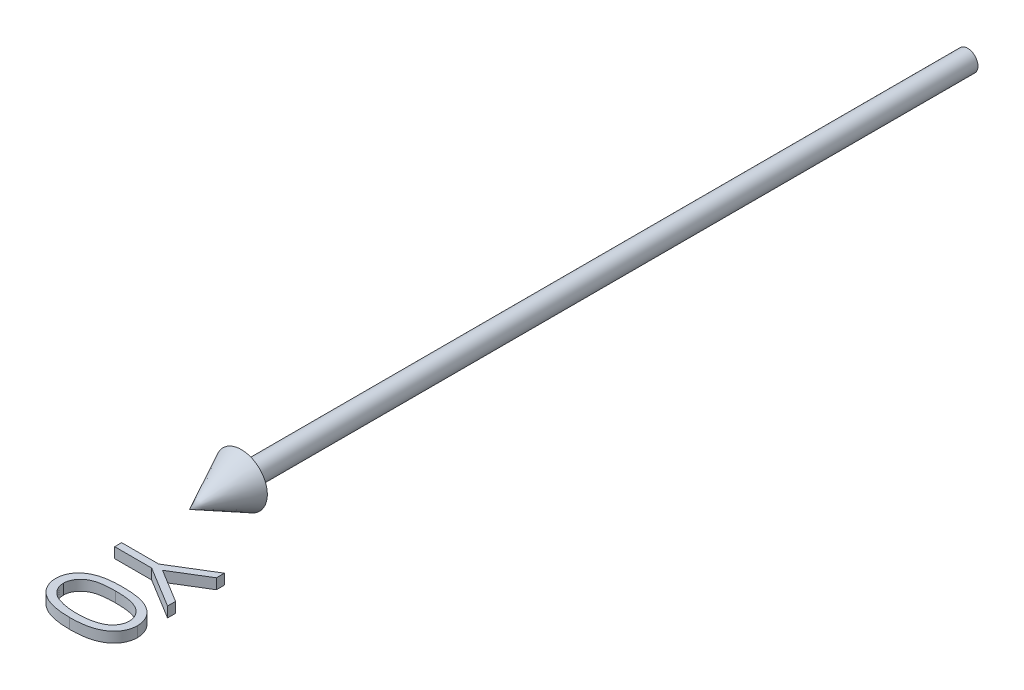
from build123d import *

# Parameters (mm, degrees)
BOSS_EXTRUDE1_DEPTH        = 1
BOSS_EXTRUDE1_DEPTH_BACK   = 1
BOSS_EXTRUDE1_2_DEPTH      = 1
BOSS_EXTRUDE1_2_DEPTH_BACK = 1


with BuildPart() as part:
    # Sketch2 → Revolve1 (revolve)
    with BuildSketch(Plane(origin=(0, 0, 0), x_dir=(1, 0, 0), z_dir=(0, 1, 0))):
        Polygon((0, -150), (5, -140), (2, -140), (2, 0), (0, 0), align=None)
    revolve(axis=Axis((0, 0, -41.949952025), (0, 0, 1)))


with BuildPart() as body_2:
    # Sketch3 → Boss-Extrude1 (new, two sides: drawn at the far end of the back side and taken through both)
    with BuildSketch(Plane(origin=(0, 0, 0), x_dir=(1, 0, 0), z_dir=(0, 1, 0)).offset(-BOSS_EXTRUDE1_DEPTH_BACK)):
        Polygon((15, -158.269230769), (15, -159.810697115), (8.5546875, -163.753004808), (15, -167.689302885), (15, -169.230769231), (7.130408654, -164.423076923), (0, -164.423076923), (0, -163.076923077), (7.130408654, -163.076923077), align=None)
    extrude(amount=BOSS_EXTRUDE1_DEPTH + BOSS_EXTRUDE1_DEPTH_BACK)


with BuildPart() as body_3:
    # Sketch3 → Boss-Extrude1 2 (new, two sides: drawn at the far end of the back side and taken through both)
    with BuildSketch(Plane(origin=(0, 0, 0), x_dir=(1, 0, 0), z_dir=(0, 1, 0)).offset(-BOSS_EXTRUDE1_2_DEPTH_BACK)):
        with BuildLine():
            add(Edge.make_bspline(
                [(7.493990385, -170.384615385), (7.734407761, -170.386021177), (8.201421979, -170.388751948), (8.881927587, -170.419130896), (9.520328829, -170.469596645), (10.116656244, -170.538756826), (10.67106384, -170.622919561), (11.182069829, -170.73527177), (11.652039951, -170.86304051), (12.082504599, -171.011123814), (12.479270571, -171.17820954), (12.849648816, -171.360087578), (13.193169112, -171.563876698), (13.51499205, -171.778277961), (13.811525932, -172.011126158), (14.082209196, -172.259965314), (14.327205285, -172.527263814), (14.549430068, -172.807735101), (14.743016183, -173.103151676), (14.917450141, -173.404406832), (15.060618757, -173.716816459), (15.178257413, -174.037531283), (15.272518287, -174.365618631), (15.33779376, -174.702434135), (15.378703934, -175.048059165), (15.382626206, -175.281334124), (15.384615385, -175.399639423)],
                knots=[0, 0, 0, 0, 1.646377244, 3.198111528, 4.663803227, 6.031090796, 7.308794487, 8.502186765, 9.612154809, 10.642545331, 11.617106989, 12.558866172, 13.465886467, 14.35053239, 15.20542558, 16.045215227, 16.865619885, 17.686225247, 18.492864914, 19.282407821, 20.068097601, 20.842842034, 21.620163247, 22.403093475, 23.190129512, 24, 24, 24, 24], degree=3))
            add(Edge.make_bspline(
                [(15.384615385, -175.399639423), (15.382524748, -175.518934331), (15.37836713, -175.756174369), (15.338407376, -176.106918834), (15.272102563, -176.449560327), (15.178155529, -176.782638065), (15.061602629, -177.108888007), (14.915514984, -177.425758325), (14.745462696, -177.735217247), (14.545646079, -178.03234705), (14.322864895, -178.320409687), (14.071024886, -178.592329529), (13.792668946, -178.848131325), (13.490775244, -179.091025491), (13.159553452, -179.314120908), (12.80476441, -179.526578475), (12.42020356, -179.716744343), (12.01228727, -179.899892951), (11.569728732, -180.057980037), (11.095022615, -180.200549659), (10.582561815, -180.315745239), (10.035035049, -180.411699263), (9.450431549, -180.486034532), (8.830004483, -180.540174426), (8.173345666, -180.568773362), (7.724383455, -180.574159224), (7.493990385, -180.576923077)],
                knots=[0, 0, 0, 0, 0.810914788, 1.612654377, 2.396697861, 3.181598691, 3.963628158, 4.749916497, 5.551656086, 6.361998678, 7.18212741, 8.025565596, 8.878627764, 9.750805457, 10.657531673, 11.591944965, 12.560506719, 13.57287815, 14.630710178, 15.753379473, 16.941251878, 18.199788006, 19.531962791, 20.947069417, 22.433333509, 24, 24, 24, 24], degree=3))
            add(Edge.make_bspline(
                [(7.493990385, -180.576923077), (7.264603065, -180.57412712), (6.817651229, -180.568679313), (6.163935199, -180.540532539), (5.546842359, -180.484828024), (4.964654956, -180.415930328), (4.420829624, -180.31778651), (3.910195243, -180.206214286), (3.437158505, -180.067541988), (2.996933984, -179.911609635), (2.59101622, -179.732435171), (2.209779717, -179.540588588), (1.855280169, -179.32943513), (1.524063192, -179.105009222), (1.219551287, -178.864179628), (0.940991864, -178.607294661), (0.688568659, -178.334158793), (0.462743585, -178.045444877), (0.265252974, -177.743640803), (0.088728132, -177.435214818), (-0.05451083, -177.114011014), (-0.175450263, -176.787167889), (-0.269613426, -176.451601462), (-0.334086308, -176.107640881), (-0.37942892, -175.756412602), (-0.382880577, -175.518975604), (-0.384615385, -175.399639423)],
                knots=[0, 0, 0, 0, 1.56130642, 3.042141888, 4.451772327, 5.777565838, 7.030558081, 8.211376819, 9.333164717, 10.383253789, 11.387583522, 12.350962576, 13.286244149, 14.193812918, 15.072134482, 15.925989337, 16.770211267, 17.600669898, 18.417446232, 19.22325363, 20.01647746, 20.807971184, 21.593601364, 22.38506573, 23.188331689, 24, 24, 24, 24], degree=3))
            add(Edge.make_bspline(
                [(-0.384615385, -175.399639423), (-0.382607064, -175.28133893), (-0.378647048, -175.048073448), (-0.338013359, -174.702378996), (-0.271753502, -174.36608879), (-0.181772946, -174.038530561), (-0.067412994, -173.719033953), (0.078048627, -173.410728753), (0.246761479, -173.109543308), (0.438703921, -172.816851937), (0.658664961, -172.538233163), (0.901935338, -172.272090663), (1.174616769, -172.025144432), (1.47234457, -171.795214565), (1.792592519, -171.577023606), (2.138515298, -171.375231471), (2.512363768, -171.193708194), (2.911320013, -171.022877938), (3.34494836, -170.87229139), (3.81742511, -170.740278675), (4.33136389, -170.63022761), (4.88523897, -170.541723973), (5.479464905, -170.468761629), (6.115087943, -170.419369857), (6.791559687, -170.388727754), (7.255574099, -170.386011189), (7.493990385, -170.384615385)],
                knots=[0, 0, 0, 0, 0.810940842, 1.599017053, 2.38298203, 3.159479784, 3.926441347, 4.70693857, 5.494146311, 6.292334103, 7.104379492, 7.925868426, 8.762126819, 9.623561095, 10.503686106, 11.41783325, 12.366995289, 13.351843594, 14.392337808, 15.512229747, 16.713911458, 17.994391108, 19.357476964, 20.818259213, 22.365182633, 24, 24, 24, 24], degree=3))
        make_face()
        with BuildLine():
            add(Edge.make_bspline(
                [(7.5, -171.730769231), (7.299648434, -171.731281147), (6.910805384, -171.732274675), (6.345762838, -171.758229821), (5.81874714, -171.793587955), (5.329089137, -171.839193526), (4.878446191, -171.906920408), (4.463719097, -171.982806775), (4.087101973, -172.075155292), (3.746012653, -172.1844211), (3.434655082, -172.308869447), (3.14495103, -172.444768924), (2.873388081, -172.590682563), (2.622724417, -172.754267227), (2.390464856, -172.93181246), (2.177276851, -173.123609805), (1.984090593, -173.329321947), (1.754856367, -173.614094986), (1.515171332, -173.988196995), (1.309023902, -174.461969146), (1.17863499, -174.949003658), (1.16209952, -175.279667143), (1.153846154, -175.444711538)],
                knots=[0, 0, 0, 0, 1.459116078, 2.831857795, 4.118796693, 5.306371758, 6.412361096, 7.436813035, 8.376339383, 9.234574298, 10.043323891, 10.816788787, 11.564361537, 12.286735248, 12.994408768, 13.691741332, 14.372975427, 15.047457468, 16.352811911, 17.594285292, 18.799233213, 20, 20, 20, 20], degree=3))
            add(Edge.make_bspline(
                [(1.153846154, -175.444711538), (1.160693786, -175.610815846), (1.174374912, -175.942681516), (1.306369501, -176.427540638), (1.50552467, -176.898241796), (1.741013979, -177.26712154), (1.965278248, -177.547761012), (2.156483884, -177.748833827), (2.370580458, -177.933385463), (2.60157744, -178.108422927), (2.853888087, -178.268961822), (3.126299124, -178.414946698), (3.419567029, -178.548161045), (3.624294482, -178.624056956), (3.728966346, -178.662860577)],
                knots=[0, 0, 0, 0, 1.353760809, 2.704726607, 4.075137775, 5.516104923, 6.260822281, 7.007110065, 7.778089737, 8.566572457, 9.372053459, 10.217411131, 11.088608312, 12, 12, 12, 12], degree=3))
            add(Edge.make_bspline(
                [(3.728966346, -178.662860577), (3.862808087, -178.708082439), (4.134564219, -178.799902212), (4.556122728, -178.918238388), (4.998420288, -179.011432956), (5.458813645, -179.095275952), (5.940698078, -179.152503334), (6.442582581, -179.198565391), (6.964845562, -179.225696907), (7.319681238, -179.229060126), (7.5, -179.230769231)],
                knots=[0, 0, 0, 0, 0.884706709, 1.796334032, 2.740027952, 3.714592787, 4.726048262, 5.777819803, 6.87074269, 8, 8, 8, 8], degree=3))
            add(Edge.make_bspline(
                [(7.5, -179.230769231), (7.680314886, -179.228884271), (8.033092983, -179.22519643), (8.549207658, -179.20096698), (9.04026198, -179.162032269), (9.50670142, -179.109334992), (9.947695768, -179.036992774), (10.363876079, -178.950116971), (10.755130158, -178.848265059), (11.122467014, -178.731437881), (11.464566341, -178.599775268), (11.782172956, -178.454327558), (12.076970622, -178.299115145), (12.348113155, -178.1304996), (12.596824432, -177.950519597), (12.818115455, -177.754415434), (13.018845343, -177.549968218), (13.247970631, -177.263608821), (13.481592187, -176.888719021), (13.696588299, -176.422237671), (13.820052411, -175.936792054), (13.837459641, -175.608620108), (13.846153846, -175.444711538)],
                knots=[0, 0, 0, 0, 1.313668642, 2.570134578, 3.763346207, 4.902004944, 5.98888779, 7.017888835, 7.998425394, 8.933058446, 9.82474457, 10.667209444, 11.476765193, 12.250262638, 12.991704352, 13.7104269, 14.401925311, 15.076585796, 16.378385137, 17.609787933, 18.806186071, 20, 20, 20, 20], degree=3))
            add(Edge.make_bspline(
                [(13.846153846, -175.444711538), (13.837458863, -175.278802035), (13.820053056, -174.94668078), (13.696912054, -174.456295073), (13.483593851, -173.986490757), (13.246461982, -173.614608662), (13.022901506, -173.328610561), (12.828492468, -173.126655973), (12.614659534, -172.937849461), (12.383383302, -172.760156311), (12.132593212, -172.596729122), (11.861069755, -172.450755767), (11.571338781, -172.3149343), (11.26005205, -172.19021877), (10.918448517, -172.081965572), (10.543732141, -171.985207181), (10.128617676, -171.909366854), (9.676714853, -171.843185372), (9.186454905, -171.792725746), (8.658224188, -171.75832059), (8.092204505, -171.732227713), (7.701355185, -171.731265129), (7.5, -171.730769231)],
                knots=[0, 0, 0, 0, 1.207964612, 2.418129846, 3.655795183, 4.951004962, 5.620895151, 6.296795572, 6.989224116, 7.696855977, 8.419187164, 9.166715907, 9.940135271, 10.748837255, 11.607021648, 12.548275234, 13.5654991, 14.678641405, 15.874140913, 17.15372626, 18.533675393, 20, 20, 20, 20], degree=3))
        make_face(mode=Mode.SUBTRACT)
    extrude(amount=BOSS_EXTRUDE1_2_DEPTH + BOSS_EXTRUDE1_2_DEPTH_BACK)


solid = Compound([part.part, body_2.part, body_3.part])
